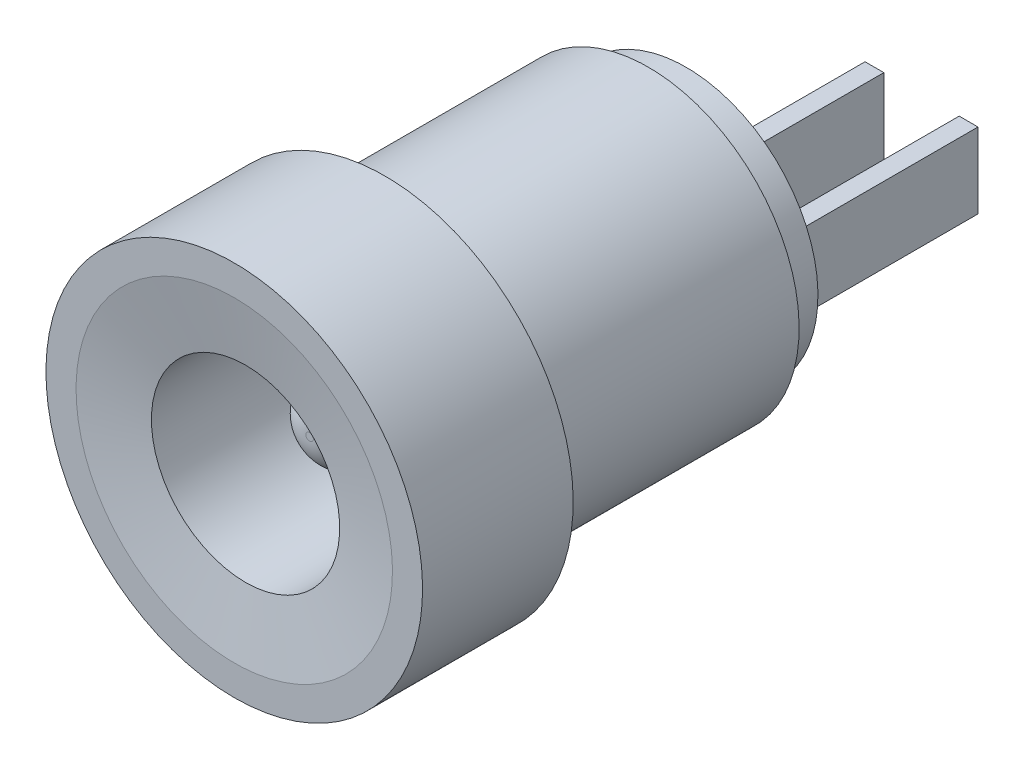
from build123d import *

# Parameters (mm, degrees)
ZAOKR_GLENIE1_R             = 1
SFAZOWANIE1_SIZE            = 0.3
SFAZOWANIE1_SIZE2           = 1.701384546
SZKIC2_W                    = 0.5
SZKIC2_H                    = 2
DODANIE_WYCI_GNI_CIE1_DEPTH = 5


with BuildPart() as part:
    # Szkic1 → Obrót1 (revolve)
    with BuildSketch(Plane(origin=(0, 0, 0), x_dir=(0, 0, -1), z_dir=(1, 0, 0))):
        Polygon((2, 0), (12, 0), (12, 3.5), (11, 3.5), (11, 4), (4, 4), (4, 5), (0, 5), (0, 2.5), (8, 2.5), (8, 1.1), (2, 1.1), align=None)
    revolve(axis=Axis((0, 0, 23.697784827), (0, 0, -1)))

    # Zaokrąglenie1
    zaokr_glenie1_edges = [part.edges().sort_by_distance(p)[0] for p in [
        (0, -1.1, -2),
    ]]
    fillet(zaokr_glenie1_edges, radius=ZAOKR_GLENIE1_R)

    # Sfazowanie1
    sfazowanie1_edges = [part.edges().sort_by_distance(p)[0] for p in [
        (0, -2.5, 0),
    ]]
    sfazowanie1_side = [part.faces().sort_by_distance(p)[0] for p in [
        (0, -2.5, -4),
    ]]
    chamfer(sfazowanie1_edges, length=SFAZOWANIE1_SIZE, length2=SFAZOWANIE1_SIZE2, reference=sfazowanie1_side[0])

    # Szkic2 → Dodanie-wyciągnięcie1 (add)
    with BuildSketch(Plane(origin=(0, 0, -12), x_dir=(-1, 0, 0), z_dir=(0, 0, -1))):
        with Locations((-2.5, 0)):
            Rectangle(SZKIC2_W, SZKIC2_H)
        Rectangle(SZKIC2_W, SZKIC2_H)
    extrude(amount=DODANIE_WYCI_GNI_CIE1_DEPTH)


solid = part.part
